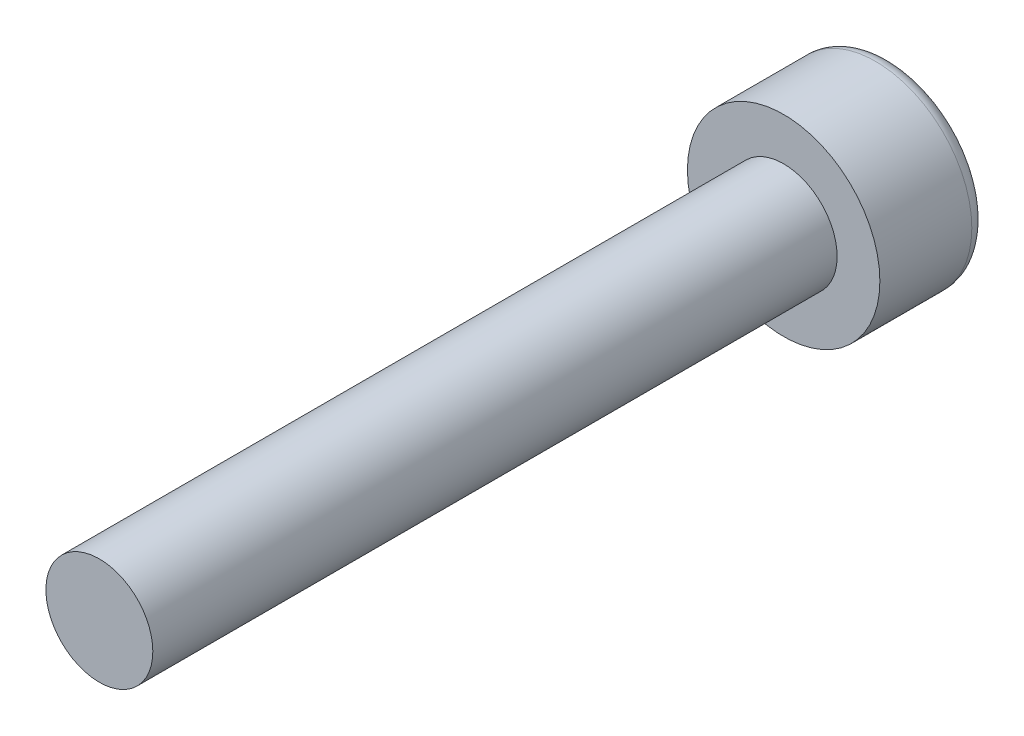
from build123d import *

# Parameters (mm, degrees)
CROQUIS1_R              = 1.25
SALIENTE_EXTRUIR1_DEPTH = 16
CROQUIS2_R              = 2.25
SALIENTE_EXTRUIR2_DEPTH = 2.5
CORTAR_EXTRUIR1_DEPTH   = 1.5
REDONDEO1_R             = 0.35


with BuildPart() as part:
    # Croquis1 → Saliente-Extruir1 (new body)
    with BuildSketch(Plane.XY):
        Circle(CROQUIS1_R)
    extrude(amount=SALIENTE_EXTRUIR1_DEPTH)

    # Croquis2 → Saliente-Extruir2 (add)
    with BuildSketch(Plane(origin=(0, 0, 0), x_dir=(-1, 0, 0), z_dir=(0, 0, -1))):
        Circle(CROQUIS2_R)
    extrude(amount=SALIENTE_EXTRUIR2_DEPTH)

    # Croquis3 → Cortar-Extruir1 (cut)
    with BuildSketch(Plane(origin=(0, 0, -2.5), x_dir=(-1, 0, 0), z_dir=(0, 0, -1))):
        Polygon((0, -1.154700538), (1, -0.577350269), (1, 0.577350269), (0, 1.154700538), (-1, 0.577350269), (-1, -0.577350269), align=None)
    extrude(amount=-CORTAR_EXTRUIR1_DEPTH, mode=Mode.SUBTRACT)

    # Redondeo1
    redondeo1_edges = [part.edges().sort_by_distance(p)[0] for p in [
        (2.25, 0, -2.5),
    ]]
    fillet(redondeo1_edges, radius=REDONDEO1_R)


solid = part.part
